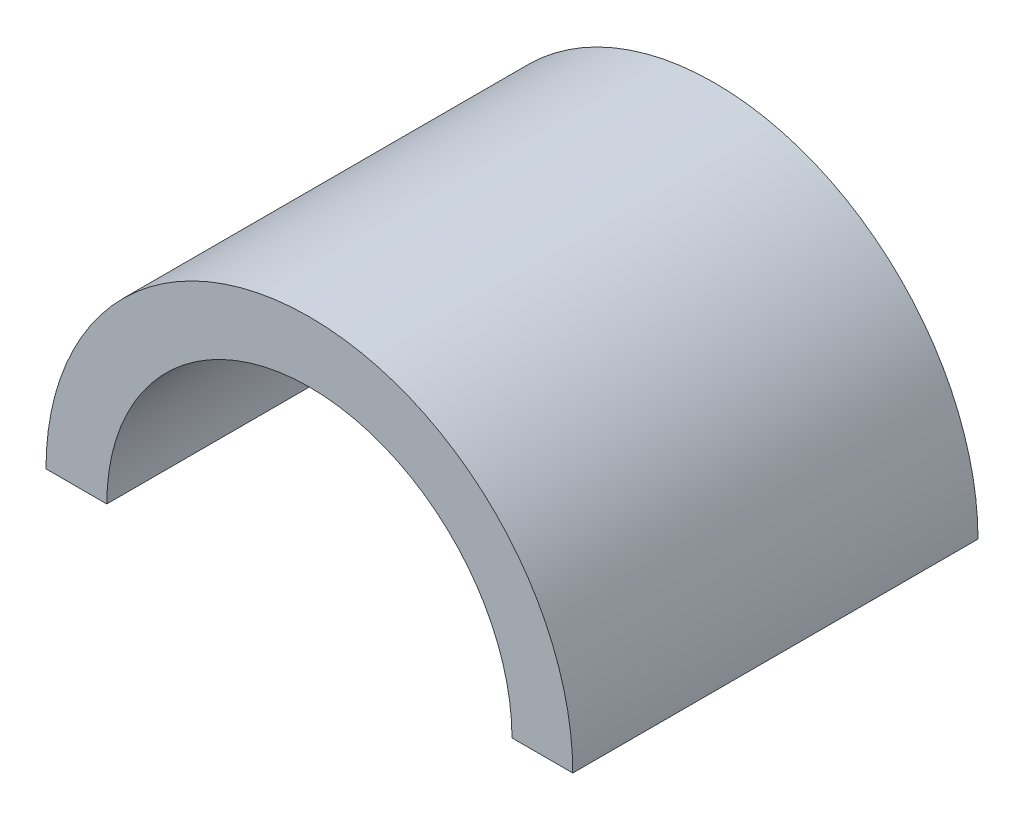
from build123d import *

# Parameters (mm, degrees)
BOSS_EXTRUDE1_DEPTH = 31.75


with BuildPart() as part:
    # Sketch1 → Boss-Extrude1 (new body, symmetric)
    with BuildSketch(Plane.XY):
        with BuildLine():
            ThreePointArc((57.15, 0), (88.9, 31.75), (120.65, 0))
            Line((120.65, 0), (130.175, 0))
            ThreePointArc((130.175, 0), (129.671322086, 6.428446187), (128.172581084, 12.7))
            ThreePointArc((128.172581084, 12.7), (88.9, 41.275), (49.627418916, 12.7))
            ThreePointArc((49.627418916, 12.7), (48.128677914, 6.428446187), (47.625, 0))
            Line((47.625, 0), (57.15, 0))
        make_face()
    extrude(amount=BOSS_EXTRUDE1_DEPTH, both=True)


solid = part.part
